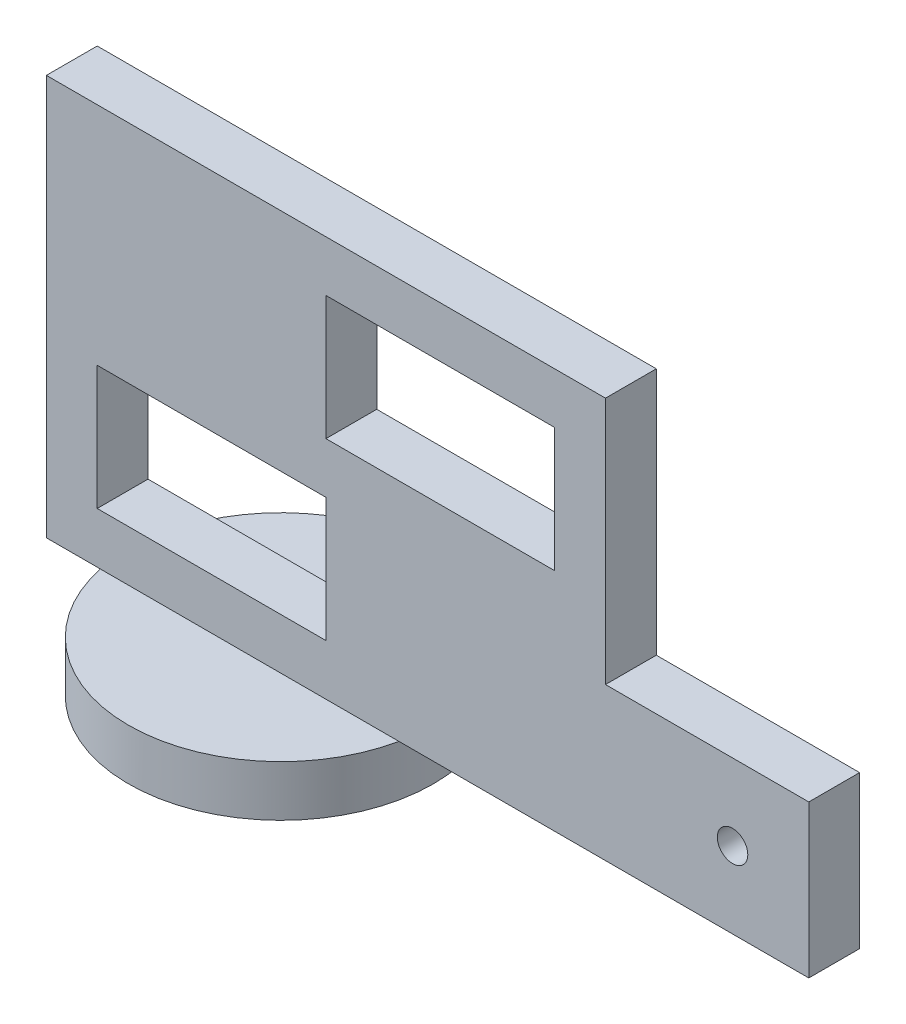
from build123d import *

# Parameters (mm, degrees)
SKETCH1_R           = 1.5
SKETCH1_W           = 22.5
SKETCH1_H           = 12.2
BOSS_EXTRUDE1_DEPTH = 5
SKETCH2_R           = 15
BOSS_EXTRUDE2_DEPTH = 5


with BuildPart() as part:
    # Sketch1 → Boss-Extrude1 (new body)
    with BuildSketch(Plane.XY):
        Polygon((0, 0), (-55, 0), (-55, 39.4), (0, 39.4), (0, 15), (20, 15), (20, 0), align=None)
        with Locations((12.5, 7.5)):
            Circle(SKETCH1_R, mode=Mode.SUBTRACT)
        with Locations((-38.75, 11.1)):
            Rectangle(SKETCH1_W, SKETCH1_H, mode=Mode.SUBTRACT)
        with Locations((-16.25, 28.3)):
            Rectangle(SKETCH1_W, SKETCH1_H, mode=Mode.SUBTRACT)
    extrude(amount=BOSS_EXTRUDE1_DEPTH)

    # Sketch2 → Boss-Extrude2 (add)
    with BuildSketch(Plane.XZ):
        with Locations((-35, 1.929670276)):
            Circle(SKETCH2_R)
    extrude(amount=BOSS_EXTRUDE2_DEPTH)


solid = part.part
